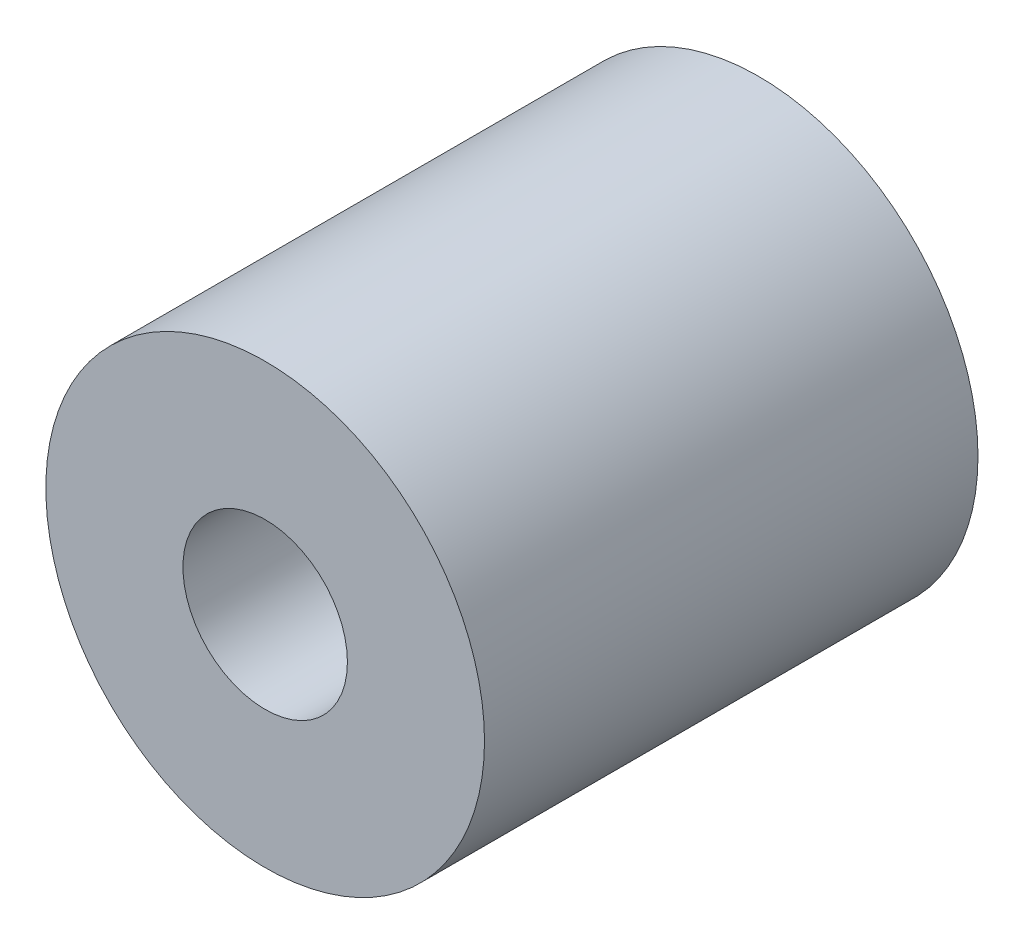
from build123d import *

# Parameters (mm, degrees)
SKETCH1_R           = 40
SKETCH1_R_2         = 15
BOSS_EXTRUDE1_DEPTH = 90


with BuildPart() as part:
    # Sketch1 → Boss-Extrude1 (new body)
    with BuildSketch(Plane.XY):
        Circle(SKETCH1_R)
        Circle(SKETCH1_R_2, mode=Mode.SUBTRACT)
    extrude(amount=BOSS_EXTRUDE1_DEPTH)


solid = part.part
